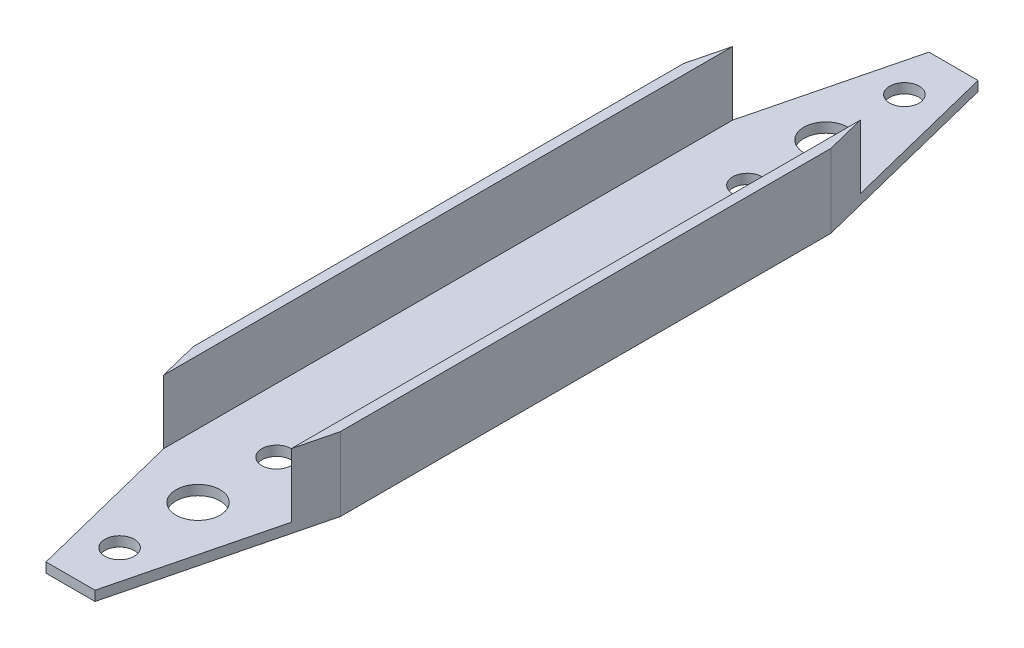
from build123d import *

# Parameters (mm, degrees)
P_IDAT_VYSUNUT_M1_DEPTH  = 180
ODEBRAT_VYSUNUT_M1_REACH = 4
SKICA2_R                 = 3
SKICA2_R_2               = 4.5
ODEBRAT_VYSUNUT_M2_DEPTH = 15


with BuildPart() as part:
    # Skica1 → Přidat vysunutím1 (new body)
    with BuildSketch(Plane.XY):
        Polygon((28, 15), (30, 15), (30, 0), (0, 0), (0, 15), (2, 15), (2, 2), (28, 2), align=None)
    extrude(amount=P_IDAT_VYSUNUT_M1_DEPTH)

    # Skica2 → Odebrat vysunutím1 (cut, up to next)
    with BuildSketch(Plane(origin=(0, 2, 0), x_dir=(1, 0, 0), z_dir=(0, 1, 0)), mode=Mode.PRIVATE) as odebrat_vysunut_m1_sk1:
        with Locations((15, -170)):
            Circle(SKICA2_R)
    odebrat_vysunut_m1_tool1 = extrude(odebrat_vysunut_m1_sk1.sketch, amount=-ODEBRAT_VYSUNUT_M1_REACH, mode=Mode.PRIVATE) & part.part
    add(odebrat_vysunut_m1_tool1.solids().sort_by_distance((15, 2, 170))[0], mode=Mode.SUBTRACT)
    # Skica2 → Odebrat vysunutím1 (cut, up to next)
    with BuildSketch(Plane(origin=(0, 2, 0), x_dir=(1, 0, 0), z_dir=(0, 1, 0)), mode=Mode.PRIVATE) as odebrat_vysunut_m1_sk2:
        with Locations((15, -154)):
            Circle(SKICA2_R_2)
    odebrat_vysunut_m1_tool2 = extrude(odebrat_vysunut_m1_sk2.sketch, amount=-ODEBRAT_VYSUNUT_M1_REACH, mode=Mode.PRIVATE) & part.part
    add(odebrat_vysunut_m1_tool2.solids().sort_by_distance((15, 2, 154))[0], mode=Mode.SUBTRACT)
    # Skica2 → Odebrat vysunutím1 (cut, up to next)
    with BuildSketch(Plane(origin=(0, 2, 0), x_dir=(1, 0, 0), z_dir=(0, 1, 0)), mode=Mode.PRIVATE) as odebrat_vysunut_m1_sk3:
        with Locations((15, -138)):
            Circle(SKICA2_R)
    odebrat_vysunut_m1_tool3 = extrude(odebrat_vysunut_m1_sk3.sketch, amount=-ODEBRAT_VYSUNUT_M1_REACH, mode=Mode.PRIVATE) & part.part
    add(odebrat_vysunut_m1_tool3.solids().sort_by_distance((15, 2, 138))[0], mode=Mode.SUBTRACT)
    # Skica2 → Odebrat vysunutím1 (cut, up to next)
    with BuildSketch(Plane(origin=(0, 2, 0), x_dir=(1, 0, 0), z_dir=(0, 1, 0)), mode=Mode.PRIVATE) as odebrat_vysunut_m1_sk4:
        with Locations((15, -42)):
            Circle(SKICA2_R)
    odebrat_vysunut_m1_tool4 = extrude(odebrat_vysunut_m1_sk4.sketch, amount=-ODEBRAT_VYSUNUT_M1_REACH, mode=Mode.PRIVATE) & part.part
    add(odebrat_vysunut_m1_tool4.solids().sort_by_distance((15, 2, 42))[0], mode=Mode.SUBTRACT)
    # Skica2 → Odebrat vysunutím1 (cut, up to next)
    with BuildSketch(Plane(origin=(0, 2, 0), x_dir=(1, 0, 0), z_dir=(0, 1, 0)), mode=Mode.PRIVATE) as odebrat_vysunut_m1_sk5:
        with Locations((15, -26)):
            Circle(SKICA2_R_2)
    odebrat_vysunut_m1_tool5 = extrude(odebrat_vysunut_m1_sk5.sketch, amount=-ODEBRAT_VYSUNUT_M1_REACH, mode=Mode.PRIVATE) & part.part
    add(odebrat_vysunut_m1_tool5.solids().sort_by_distance((15, 2, 26))[0], mode=Mode.SUBTRACT)
    # Skica2 → Odebrat vysunutím1 (cut, up to next)
    with BuildSketch(Plane(origin=(0, 2, 0), x_dir=(1, 0, 0), z_dir=(0, 1, 0)), mode=Mode.PRIVATE) as odebrat_vysunut_m1_sk6:
        with Locations((15, -10)):
            Circle(SKICA2_R)
    odebrat_vysunut_m1_tool6 = extrude(odebrat_vysunut_m1_sk6.sketch, amount=-ODEBRAT_VYSUNUT_M1_REACH, mode=Mode.PRIVATE) & part.part
    add(odebrat_vysunut_m1_tool6.solids().sort_by_distance((15, 2, 10))[0], mode=Mode.SUBTRACT)

    # Skica3 → Odebrat vysunutím2 (cut)
    with BuildSketch(Plane.XZ):
        Polygon((30, 180), (20, 180), (30, 140), align=None)
        Polygon((0, 0), (10, 0), (0, 40), align=None)
        Polygon((10, 180), (0, 140), (0, 180), align=None)
        Polygon((20, 0), (30, 40), (30, 0), align=None)
    extrude(amount=-ODEBRAT_VYSUNUT_M2_DEPTH, mode=Mode.SUBTRACT)


solid = part.part
